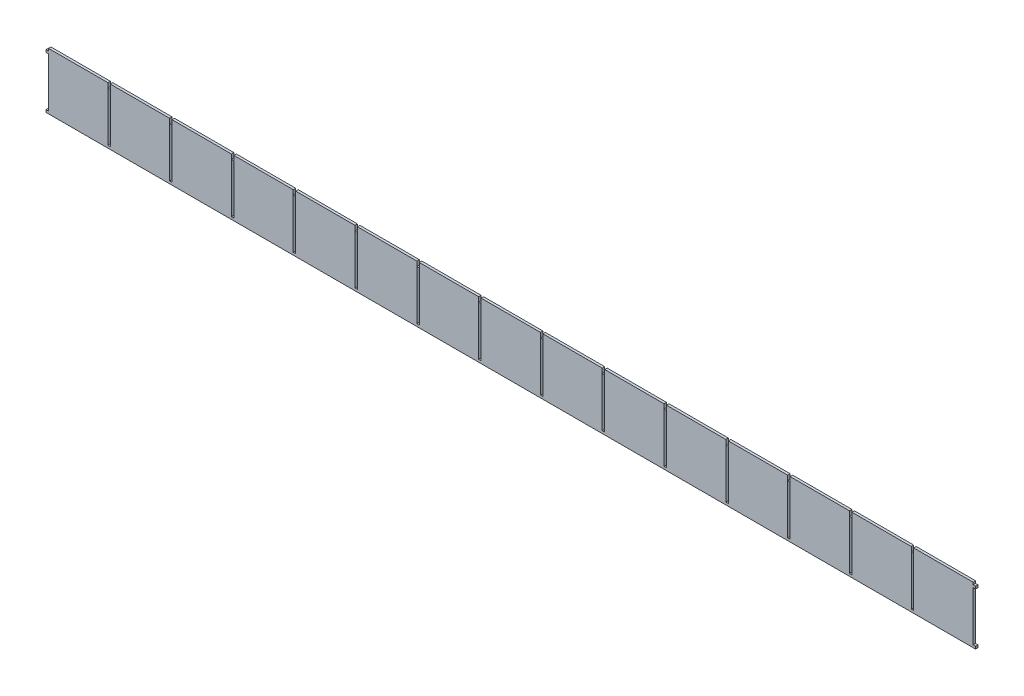
from build123d import *

# Parameters (mm, degrees)
SKETCH1_W           = 4
SKETCH1_H           = 80.123518492
BOSS_EXTRUDE1_DEPTH = 4


with BuildPart() as part:
    # Sketch1 → Boss-Extrude1 (new body)
    with BuildSketch(Plane.XY):
        Polygon((-652, 45.888948558), (-748, 45.888948558), (-748, 42.134569934), (-752, 42.134569934), (-752, 38.278329491), (-748, 38.278329491), (-748, -41.888948558), (-752, -41.888948558), (-752, -45.888948558), (752, -45.888948558), (752, -41.888948558), (748, -41.888948558), (748, 38.234569934), (752, 38.234569934), (752, 42.134569934), (748, 42.134569934), (748, 45.888948558), (652, 45.888948558), (652, 42.134569934), (652, 38.278329491), (648, 38.278329491), (648, 42.134569934), (648, 45.888948558), (552, 45.888948558), (552, 42.134569934), (552, 38.278329491), (548, 38.278329491), (548, 42.134569934), (548, 45.888948558), (452, 45.888948558), (452, 42.134569934), (452, 38.278329491), (448, 38.278329491), (448, 42.134569934), (448, 45.888948558), (352, 45.888948558), (352, 42.134569934), (352, 38.278329491), (348, 38.278329491), (348, 42.134569934), (348, 45.888948558), (252, 45.888948558), (252, 42.134569934), (252, 38.278329491), (248, 38.278329491), (248, 42.134569934), (248, 45.888948558), (152, 45.888948558), (152, 42.134569934), (152, 38.278329491), (148, 38.278329491), (148, 42.134569934), (148, 45.888948558), (52, 45.888948558), (52, 42.134569934), (52, 38.278329491), (48, 38.278329491), (48, 42.134569934), (48, 45.888948558), (-48, 45.888948558), (-48, 42.134569934), (-48, 38.278329491), (-52, 38.278329491), (-52, 42.134569934), (-52, 45.888948558), (-148, 45.888948558), (-148, 42.134569934), (-148, 38.278329491), (-152, 38.278329491), (-152, 42.134569934), (-152, 45.888948558), (-248, 45.888948558), (-248, 42.134569934), (-248, 38.278329491), (-252, 38.278329491), (-252, 42.134569934), (-252, 45.888948558), (-348, 45.888948558), (-348, 42.134569934), (-348, 38.278329491), (-352, 38.278329491), (-352, 42.134569934), (-352, 45.888948558), (-448, 45.888948558), (-448, 42.134569934), (-448, 38.278329491), (-452, 38.278329491), (-452, 42.134569934), (-452, 45.888948558), (-548, 45.888948558), (-548, 42.134569934), (-548, 38.278329491), (-552, 38.278329491), (-552, 42.134569934), (-552, 45.888948558), (-648, 45.888948558), (-648, 42.134569934), (-648, 38.278329491), (-652, 38.278329491), (-652, 42.134569934), align=None)
        with Locations((-650, -1.827189312)):
            Rectangle(SKETCH1_W, SKETCH1_H, mode=Mode.SUBTRACT)
        with Locations((-550, -1.827189312)):
            Rectangle(SKETCH1_W, SKETCH1_H, mode=Mode.SUBTRACT)
        with Locations((-450, -1.827189312)):
            Rectangle(SKETCH1_W, SKETCH1_H, mode=Mode.SUBTRACT)
        with Locations((-350, -1.827189312)):
            Rectangle(SKETCH1_W, SKETCH1_H, mode=Mode.SUBTRACT)
        with Locations((-250, -1.827189312)):
            Rectangle(SKETCH1_W, SKETCH1_H, mode=Mode.SUBTRACT)
        with Locations((-150, -1.827189312)):
            Rectangle(SKETCH1_W, SKETCH1_H, mode=Mode.SUBTRACT)
        with Locations((-50, -1.827189312)):
            Rectangle(SKETCH1_W, SKETCH1_H, mode=Mode.SUBTRACT)
        with Locations((50, -1.827189312)):
            Rectangle(SKETCH1_W, SKETCH1_H, mode=Mode.SUBTRACT)
        with Locations((150, -1.827189312)):
            Rectangle(SKETCH1_W, SKETCH1_H, mode=Mode.SUBTRACT)
        with Locations((250, -1.827189312)):
            Rectangle(SKETCH1_W, SKETCH1_H, mode=Mode.SUBTRACT)
        with Locations((350, -1.827189312)):
            Rectangle(SKETCH1_W, SKETCH1_H, mode=Mode.SUBTRACT)
        with Locations((450, -1.827189312)):
            Rectangle(SKETCH1_W, SKETCH1_H, mode=Mode.SUBTRACT)
        with Locations((550, -1.827189312)):
            Rectangle(SKETCH1_W, SKETCH1_H, mode=Mode.SUBTRACT)
        with Locations((650, -1.827189312)):
            Rectangle(SKETCH1_W, SKETCH1_H, mode=Mode.SUBTRACT)
    extrude(amount=BOSS_EXTRUDE1_DEPTH)


solid = part.part
